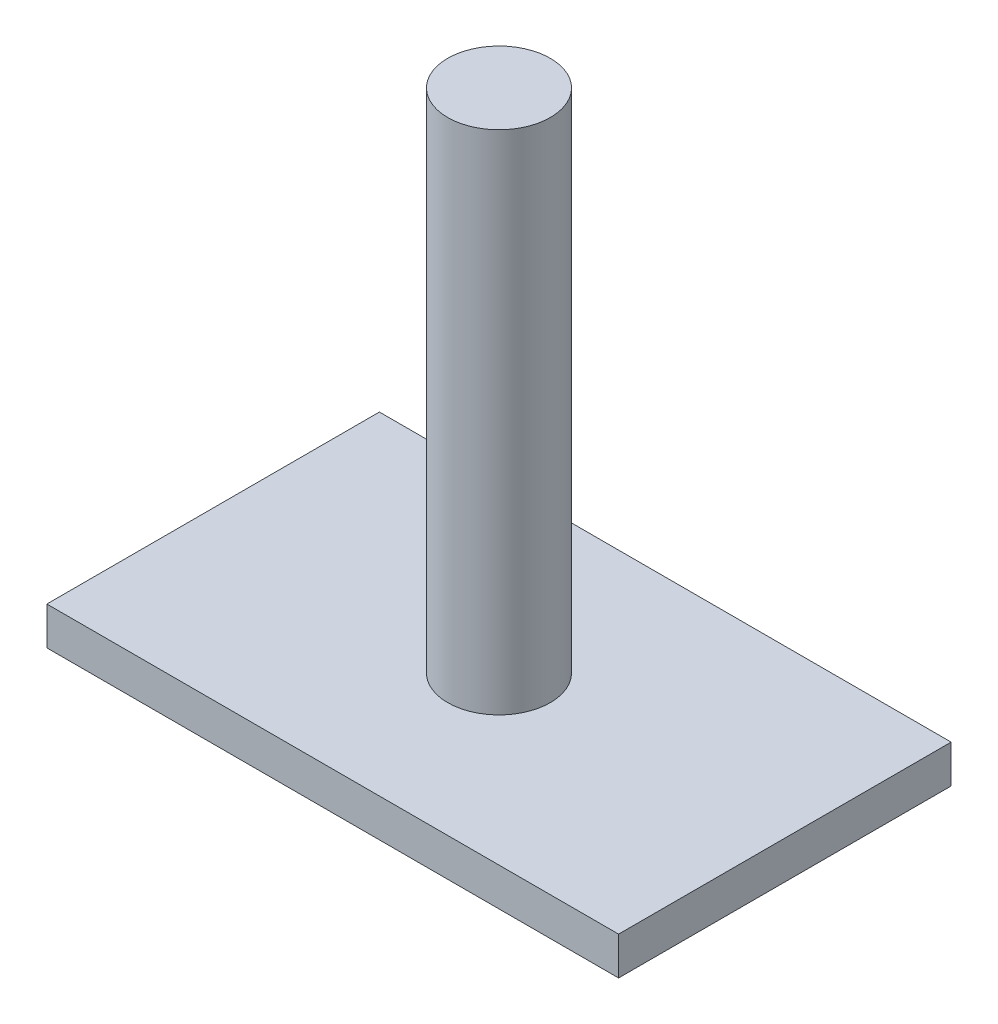
from build123d import *

# Parameters (mm, degrees)
SKETCH1_R           = 4.05
BOSS_EXTRUDE1_DEPTH = 40
SKETCH2_W           = 45.127997656
SKETCH2_H           = 26.248845412
BOSS_EXTRUDE2_DEPTH = 3


with BuildPart() as part:
    # Sketch1 → Boss-Extrude1 (new body)
    with BuildSketch(Plane(origin=(0, 0, 0), x_dir=(1, 0, 0), z_dir=(0, 1, 0))):
        Circle(SKETCH1_R)
    extrude(amount=BOSS_EXTRUDE1_DEPTH)

    # Sketch2 → Boss-Extrude2 (add)
    with BuildSketch(Plane.XZ):
        Rectangle(SKETCH2_W, SKETCH2_H)
    extrude(amount=BOSS_EXTRUDE2_DEPTH)


solid = part.part
